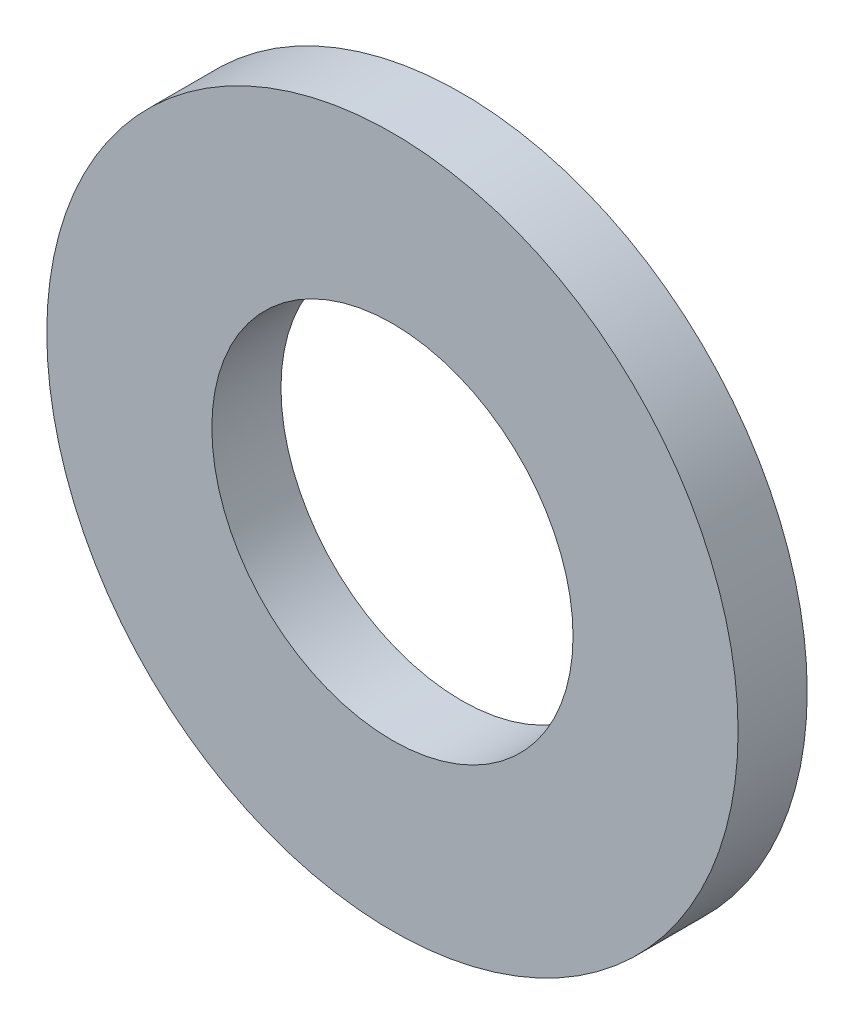
from build123d import *

# Parameters (mm, degrees)
SKETCH1_R          = 4
SKETCH1_R_2        = 2.09
BASE_EXTRUDE_DEPTH = 0.8


with BuildPart() as part:
    # Sketch1 → Base-Extrude (new body)
    with BuildSketch(Plane.XY):
        Circle(SKETCH1_R)
        Circle(SKETCH1_R_2, mode=Mode.SUBTRACT)
    extrude(amount=-BASE_EXTRUDE_DEPTH)


solid = part.part
